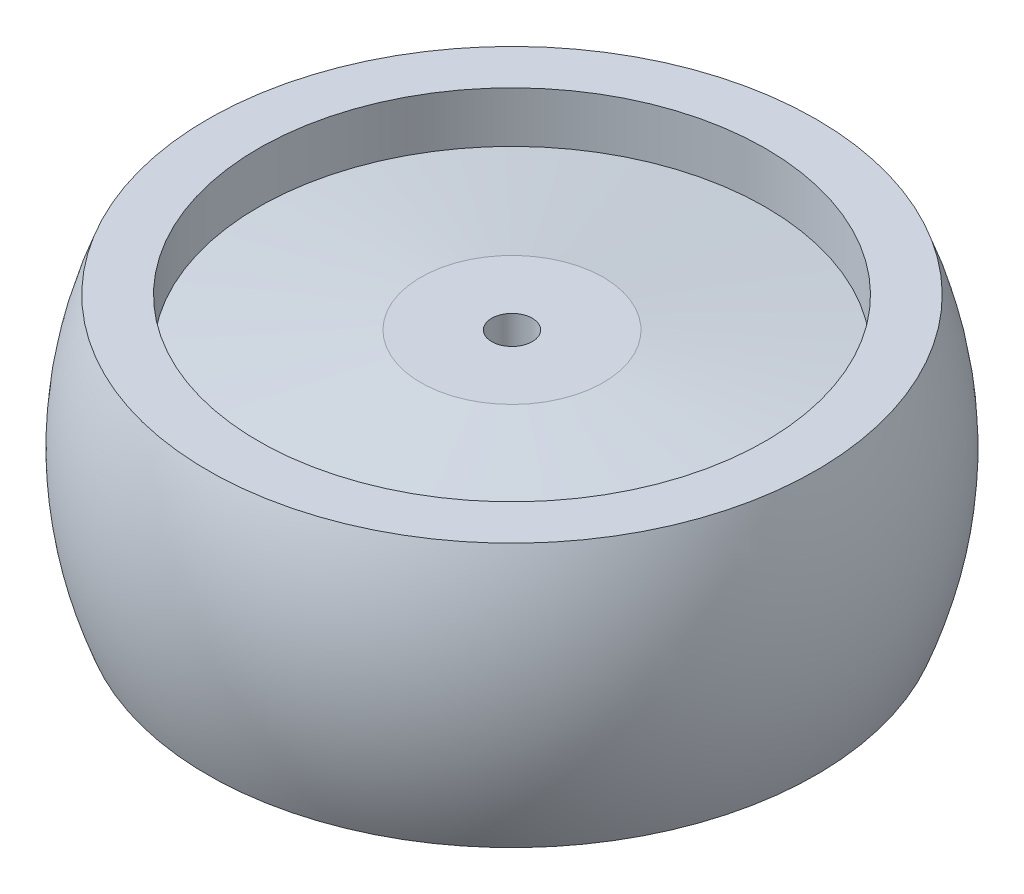
from build123d import *

# Parameters (mm, degrees)
SKETCH2_R           = 8
BOSS_EXTRUDE1_DEPTH = 6
CUT_EXTRUDE1_DEPTH  = 5
SKETCH4_R           = 2
CUT_EXTRUDE2_DEPTH  = 10.0000001


with BuildPart() as part:
    # Sketch1 → Revolve1 (revolve)
    with BuildSketch(Plane.XY):
        with BuildLine():
            Line((-30, -13), (-30, 13))
            add(Edge.make_bspline(
                [(-30, 13), (-35, 0), (-30, -13)],
                knots=[0, 0, 0, 1, 1, 1], degree=2))
        make_face()
        Polygon((-25, 3.968871126), (-25, 8), (-25, 13), (-30, 13), (-30, -13), (-25, -13), align=None)
        Polygon((-9, 10), (-25, 8), (-25, 3.968871126), (-9, 5.968871126), align=None)
        Polygon((0, 10), (-9, 10), (-9, 5.968871126), (-9, 5), (0, 5), align=None)
    revolve(axis=Axis((0, -13, 0), (0, 1, 0)))

    # Sketch2 → Boss-Extrude1 (add)
    with BuildSketch(Plane.XZ.offset(-5)):
        Circle(SKETCH2_R)
    extrude(amount=BOSS_EXTRUDE1_DEPTH)

    # Sketch3 → Cut-Extrude1 (cut)
    with BuildSketch(Plane.XZ.offset(1)):
        Polygon((6.92820323, 0), (3.464101615, 6), (-3.464101615, 6), (-6.92820323, 0), (-3.464101615, -6), (3.464101615, -6), align=None)
    extrude(amount=-CUT_EXTRUDE1_DEPTH, mode=Mode.SUBTRACT)

    # Sketch4 → Cut-Extrude2 (cut, through all)
    with BuildSketch(Plane.XZ.offset(-4)):
        Circle(SKETCH4_R)
    extrude(amount=-CUT_EXTRUDE2_DEPTH, mode=Mode.SUBTRACT)


solid = part.part
